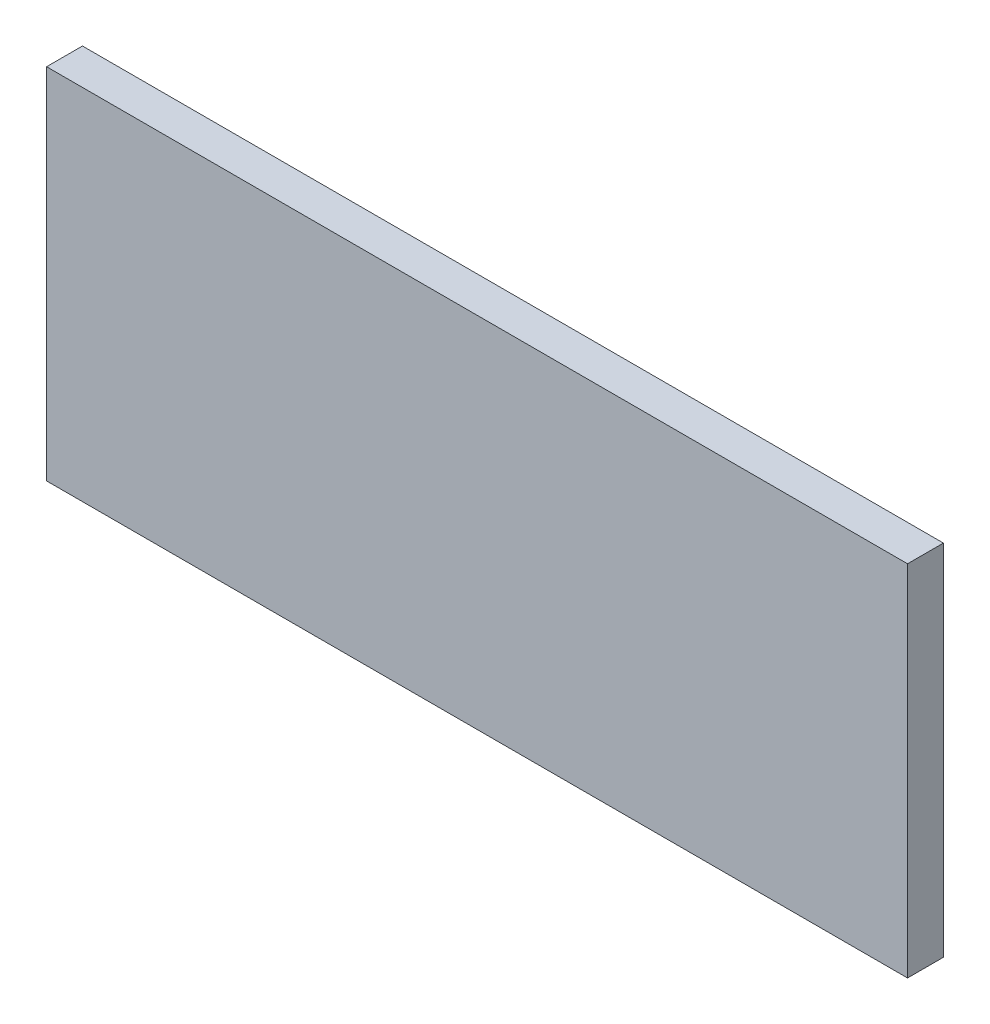
from build123d import *

# Parameters (mm, degrees)
SKETCH1_W           = 304.8
SKETCH1_H           = 127
BOSS_EXTRUDE1_DEPTH = 12.7


with BuildPart() as part:
    # Sketch1 → Boss-Extrude1 (new body)
    with BuildSketch(Plane.XY):
        with Locations((152.4, -63.5)):
            Rectangle(SKETCH1_W, SKETCH1_H)
    extrude(amount=BOSS_EXTRUDE1_DEPTH)


solid = part.part
